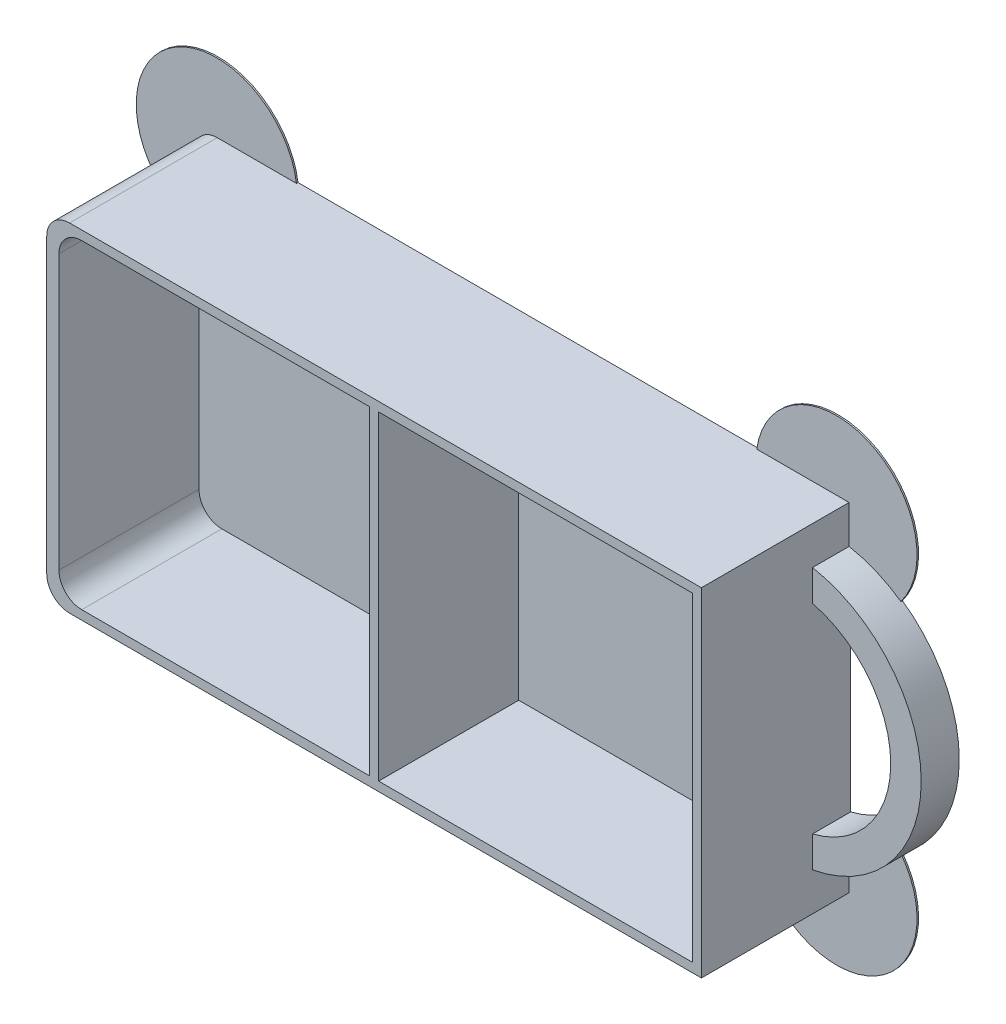
from build123d import *

# Parameters (mm, degrees)
SKETCH_1_W          = 86
SKETCH_1_H          = 44.4
EXTRUDE_1_DEPTH     = 19.6
EXTRUDE_2_DEPTH     = 5
SKETCH_3_W          = 40.8
SKETCH_3_H          = 42
SKETCH_3_W_2        = 41.2
CUT_EXTRUDE_1_DEPTH = 18.4
FILLET_1_R          = 3
EXTRUDE_3_DEPTH     = 0.2


with BuildPart() as part:
    # Эскиз1 → Бобышка-Вытянуть1 (new body)
    with BuildSketch(Plane.XY):
        Rectangle(SKETCH_1_W, SKETCH_1_H)
    extrude(amount=EXTRUDE_1_DEPTH)

    # Эскиз2 → Бобышка-Вытянуть2 (add)
    with BuildSketch(Plane.XY):
        with BuildLine():
            Line((43, 17.2), (43, 13.108775687))
            ThreePointArc((43, 13.108775687), (53.273546839, 0), (43, -13.108775687))
            Line((43, -13.108775687), (43, -17.2))
            ThreePointArc((43, -17.2), (57.273546839, 0), (43, 17.2))
        make_face()
    extrude(amount=EXTRUDE_2_DEPTH)

    # Эскиз3 → Вырез-Вытянуть1 (cut)
    with BuildSketch(Plane.XY.offset(19.6)):
        with Locations((-21, 0)):
            Rectangle(SKETCH_3_W, SKETCH_3_H)
        with Locations((21.2, 0)):
            Rectangle(SKETCH_3_W_2, SKETCH_3_H)
    extrude(amount=-CUT_EXTRUDE_1_DEPTH, mode=Mode.SUBTRACT)

    # Скругление1
    fillet_1_edges = [part.edges().sort_by_distance(p)[0] for p in [
        (-41.4, -21, 10.4),
        (-41.4, 21, 10.4),
        (-43, -22.2, 9.8),
        (-43, 22.2, 9.8),
    ]]
    fillet(fillet_1_edges, radius=FILLET_1_R)

    # Эскиз4 → Бобышка-Вытянуть3 (add)
    with BuildSketch(Plane(origin=(0, 0, 0), x_dir=(-1, 0, 0), z_dir=(0, 0, -1))):
        with BuildLine():
            Line((-49.811541671, 14.334875645), (-30.869317388, 22.2))
            ThreePointArc((-30.869317388, 22.2), (-45.401918337, 30.45743659), (-49.811541671, 14.334875645))
        make_face()
        with BuildLine():
            Line((43, 10.515346091), (29.589006911, 22.2))
            ThreePointArc((29.589006911, 22.2), (47.015516822, 28.662653345), (43, 10.515346091))
        make_face()
        with BuildLine():
            Line((43, -10.515346091), (29.589006911, -22.2))
            ThreePointArc((29.589006911, -22.2), (47.015516822, -28.662653345), (43, -10.515346091))
        make_face()
        with BuildLine():
            Line((-49.811541671, -14.334875645), (-30.869317388, -22.2))
            ThreePointArc((-30.869317388, -22.2), (-45.401918337, -30.45743659), (-49.811541671, -14.334875645))
        make_face()
    extrude(amount=-EXTRUDE_3_DEPTH)


solid = part.part
